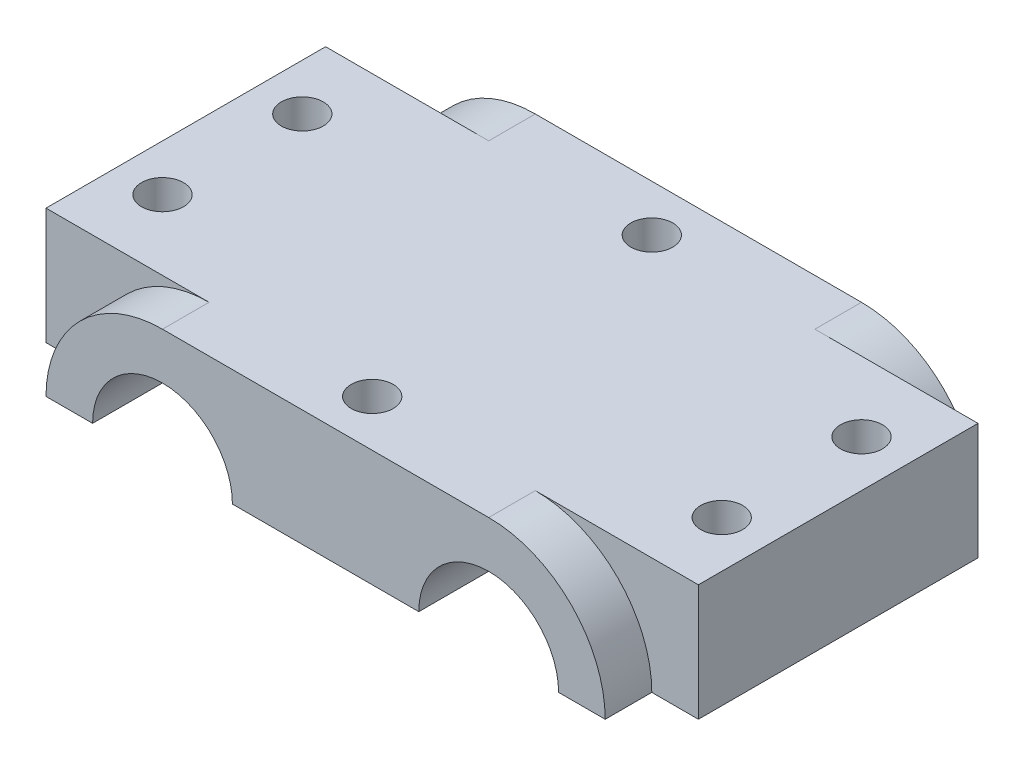
from build123d import *

# Parameters (mm, degrees)
BOSS_EXTRUDE1_DEPTH = 30
BOSS_EXTRUDE2_DEPTH = 5
BOSS_EXTRUDE3_DEPTH = 5
SKETCH5_R           = 2.25
CUT_EXTRUDE1_DEPTH  = 12.5


with BuildPart() as part:
    # Sketch2 → Boss-Extrude1 (new body)
    with BuildSketch(Plane.XY):
        with BuildLine():
            Line((0, 0), (0, 12.5))
            Line((0, 12.5), (70, 12.5))
            Line((70, 12.5), (70, 0))
            Line((70, 0), (60, 0))
            ThreePointArc((60, 0), (52.5, 7.5), (45, 0))
            Line((45, 0), (25, 0))
            ThreePointArc((25, 0), (17.5, 7.5), (10, 0))
            Line((10, 0), (0, 0))
        make_face()
    extrude(amount=BOSS_EXTRUDE1_DEPTH)

    # Sketch3 → Boss-Extrude2 (add)
    with BuildSketch(Plane.XY.offset(30)):
        with BuildLine():
            Line((17.5, 12.5), (52.5, 12.5))
            ThreePointArc((52.5, 12.5), (61.338834765, 8.838834765), (65, 0))
            Line((65, 0), (60, 0))
            ThreePointArc((60, 0), (52.5, 7.5), (45, 0))
            Line((45, 0), (25, 0))
            ThreePointArc((25, 0), (17.5, 7.5), (10, 0))
            Line((10, 0), (5, 0))
            ThreePointArc((5, 0), (8.661165235, 8.838834765), (17.5, 12.5))
        make_face()
    extrude(amount=BOSS_EXTRUDE2_DEPTH)

    # Sketch4 → Boss-Extrude3 (add)
    with BuildSketch(Plane(origin=(0, 0, 0), x_dir=(-1, 0, 0), z_dir=(0, 0, -1))):
        with BuildLine():
            Line((-65, 0), (-60, 0))
            ThreePointArc((-60, 0), (-52.5, 7.5), (-45, 0))
            Line((-45, 0), (-25, 0))
            ThreePointArc((-25, 0), (-17.5, 7.5), (-10, 0))
            Line((-10, 0), (-5, 0))
            ThreePointArc((-5, 0), (-8.661165235, 8.838834765), (-17.5, 12.5))
            Line((-17.5, 12.5), (-52.5, 12.5))
            ThreePointArc((-52.5, 12.5), (-61.338834765, 8.838834765), (-65, 0))
        make_face()
    extrude(amount=BOSS_EXTRUDE3_DEPTH)

    # Sketch5 → Cut-Extrude1 (cut)
    with BuildSketch(Plane(origin=(0, 12.5, 0), x_dir=(1, 0, 0), z_dir=(0, 1, 0))):
        with Locations((35, 0)):
            Circle(SKETCH5_R)
        with Locations((35, -30)):
            Circle(SKETCH5_R)
        with Locations((65, -7.5)):
            Circle(SKETCH5_R)
        with Locations((65, -22.5)):
            Circle(SKETCH5_R)
        with Locations((5, -22.5)):
            Circle(SKETCH5_R)
        with Locations((5, -7.5)):
            Circle(SKETCH5_R)
    extrude(amount=-CUT_EXTRUDE1_DEPTH, mode=Mode.SUBTRACT)


solid = part.part
